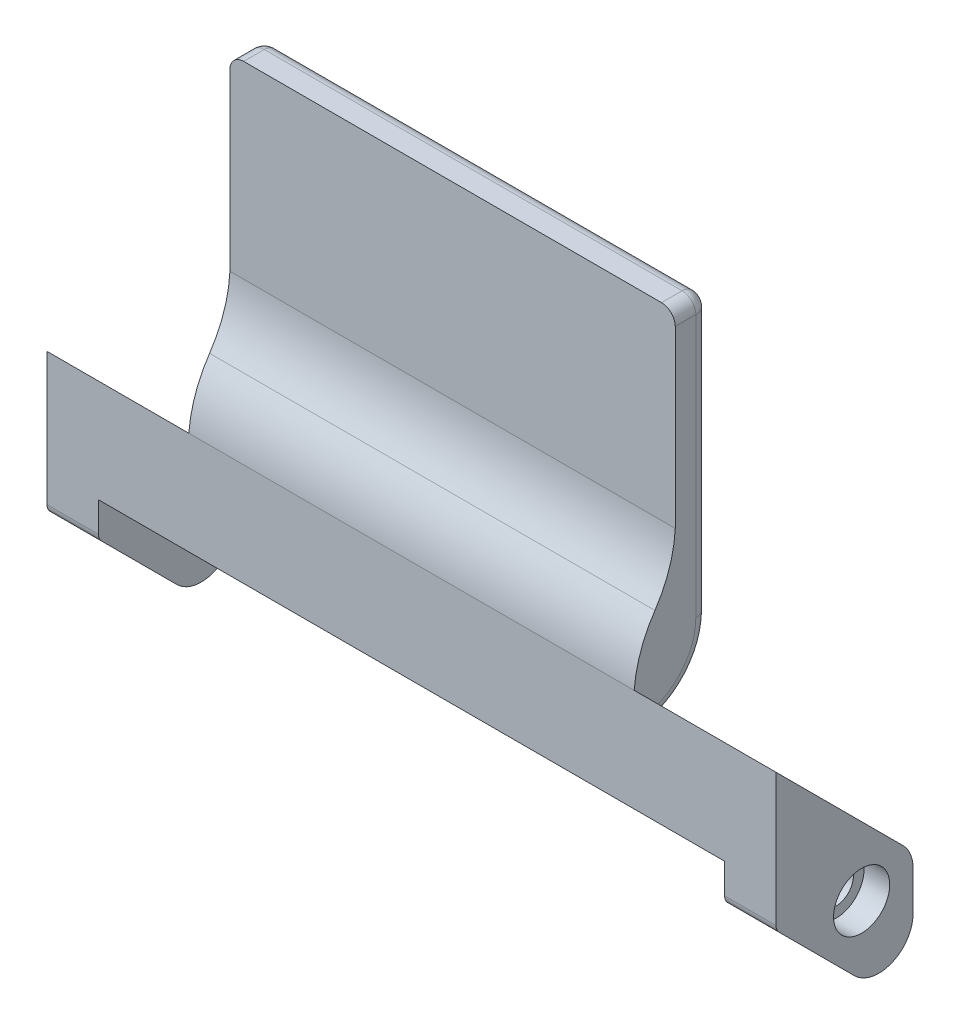
from build123d import *

# Parameters (mm, degrees)
SKETCH1_W           = 65
SKETCH1_H           = 65
BOSS_EXTRUDE1_DEPTH = 5
BOSS_EXTRUDE3_DEPTH = 7.5
BOSS_EXTRUDE5_DEPTH = 85.7
SKETCH8_R           = 2.55
CUT_EXTRUDE4_DEPTH  = 102.615648401
SKETCH8_3_R         = 4.1
SKETCH8_3_R_2       = 2.55
CUT_EXTRUDE5_DEPTH  = 3.75
SKETCH9_R           = 2.55
BOSS_EXTRUDE6_DEPTH = 7.5
SKETCH10_R          = 4.1
CUT_EXTRUDE6_DEPTH  = 3.75
BOSS_EXTRUDE7_DEPTH = 32.5
CUT_EXTRUDE7_DEPTH  = 32.5
FILLET1_R           = 5
SKETCH14_W          = 91.4
SKETCH14_H          = 5
CUT_EXTRUDE8_DEPTH  = 10
FILLET2_R           = 1.5
FILLET7_R           = 2
BOSS_EXTRUDE9_DEPTH = 65
FILLET9_R           = 2


with BuildPart() as part:
    # Sketch1 → Boss-Extrude1 (new body)
    with BuildSketch(Plane.XY):
        Rectangle(SKETCH1_W, SKETCH1_H)
    extrude(amount=BOSS_EXTRUDE1_DEPTH)



with BuildPart() as body_2:
    # Sketch4 → Boss-Extrude3 (new body)
    with BuildSketch(Plane.ZY.offset(53.2)):
        Polygon((5, -12.5), (-15, -32.5), (-15, -52.5), (5, -32.5), align=None)
    extrude(amount=-BOSS_EXTRUDE3_DEPTH)


with BuildPart() as part_1:
    add(part.part)

    add(body_2.part)  # Boss-Extrude5 merges body 2
    # Sketch7 → Boss-Extrude5 (add)
    with BuildSketch(Plane(origin=(-53.2, 0, 0), x_dir=(0, 0, -1), z_dir=(1, 0, 0))):
        Polygon((-5, -32.5), (0, -32.5), (0, -17.5), (-5, -12.5), align=None)
    boss_extrude5 = extrude(amount=BOSS_EXTRUDE5_DEPTH)

    # Sketch8 → Cut-Extrude4 (cut, through all)
    with BuildSketch(Plane.ZY.offset(53.2)):
        with Locations((-7.5, -35)):
            Circle(SKETCH8_R)
    extrude(amount=-CUT_EXTRUDE4_DEPTH, mode=Mode.SUBTRACT)

    # Sketch8_3 → Cut-Extrude5 (cut)
    with BuildSketch(Plane.ZY.offset(53.2)):
        with Locations((-7.5, -35)):
            Circle(SKETCH8_3_R)
        with Locations((-7.5, -35)):
            Circle(SKETCH8_3_R_2, mode=Mode.SUBTRACT)
    extrude(amount=-CUT_EXTRUDE5_DEPTH, mode=Mode.SUBTRACT)

    # Mirror5: Boss-Extrude5 across plane
    add(boss_extrude5.mirror(Plane(origin=(0, 0, 0), x_dir=(0, 0, 1), z_dir=(1, 0, 0))))

    # Sketch9 → Boss-Extrude6 (add)
    with BuildSketch(Plane(origin=(53.2, 0, 0), x_dir=(0, 0, -1), z_dir=(1, 0, 0))):
        Polygon((0, -17.5), (-5, -12.5), (-5, -32.5), (15, -52.5), (15, -32.5), align=None)
        with Locations(Location((7.5, -35, 0), (0, 0, 180))):
            Circle(SKETCH9_R, mode=Mode.SUBTRACT)
    extrude(amount=-BOSS_EXTRUDE6_DEPTH)

    # Sketch10 → Cut-Extrude6 (cut)
    with BuildSketch(Plane(origin=(53.2, 0, 0), x_dir=(0, 0, -1), z_dir=(1, 0, 0))):
        with Locations(Location((7.5, -35, 0), (0, 0, 180))):
            Circle(SKETCH10_R)
    extrude(amount=-CUT_EXTRUDE6_DEPTH, mode=Mode.SUBTRACT)

    # Sketch11 → Boss-Extrude7 (add, symmetric)
    with BuildSketch(Plane(origin=(0, 0, 0), x_dir=(0, 0, -1), z_dir=(1, 0, 0))):
        with BuildLine():
            Line((-5, -12.5), (-5, -32.5))
            Line((-5, -32.5), (0, -32.5))
            Line((0, -32.5), (0, -17.5))
            ThreePointArc((0, -17.5), (1.245268577, -11.245121626), (3.482006161, -5.272584286))
            ThreePointArc((3.482006161, -5.272584286), (5.362849311, 0.228699546), (6, 6.007603745))
            Line((6, 6.007603745), (6, 32.5))
            Line((6, 32.5), (1, 32.5))
            Line((1, 32.5), (1, 4.967162469))
            ThreePointArc((1, 4.967162469), (0.129503325, 0.320168795), (-1.970810175, -3.915512716))
            ThreePointArc((-1.970810175, -3.915512716), (-4.043682345, -8.010758246), (-5, -12.5))
        make_face()
    extrude(amount=BOSS_EXTRUDE7_DEPTH, both=True)

    # Sketch13 → Cut-Extrude7 (cut, symmetric)
    with BuildSketch(Plane(origin=(0, 0, 0), x_dir=(0, 0, -1), z_dir=(1, 0, 0))):
        with BuildLine():
            ThreePointArc((-1.970810175, -3.915512716), (-4.043682345, -8.010758246), (-5, -12.5))
            Line((-5, -12.5), (-5, 32.5))
            Line((-5, 32.5), (1, 32.5))
            Line((1, 32.5), (1, 4.967162469))
            ThreePointArc((1, 4.967162469), (0.129503325, 0.320168795), (-1.970810175, -3.915512716))
        make_face()
    extrude(amount=CUT_EXTRUDE7_DEPTH, both=True, mode=Mode.SUBTRACT)

    # Fillet1
    fillet1_edges = [part_1.edges().sort_by_distance(p)[0] for p in [
        (-49.45, -32.5, -15),
        (-49.45, -52.5, -15),
        (49.45, -32.5, -15),
        (49.45, -52.5, -15),
    ]]
    fillet(fillet1_edges, radius=FILLET1_R)

    # Sketch14 → Cut-Extrude8 (cut)
    with BuildSketch(Plane.XY.offset(5)):
        with Locations((0, -30)):
            Rectangle(SKETCH14_W, SKETCH14_H)
    extrude(amount=-CUT_EXTRUDE8_DEPTH, mode=Mode.SUBTRACT)

    # Fillet2
    fillet2_edges = [part_1.edges().sort_by_distance(p)[0] for p in [
        (0, -27.5, 0),
        (49.45, -32.5, 5),
        (-49.45, -32.5, 5),
    ]]
    fillet(fillet2_edges, radius=FILLET2_R)

    # Fillet7
    fillet7_edges = [part_1.edges().sort_by_distance(p)[0] for p in [
        (32.5, 32.5, -3.5),
        (-32.5, 32.5, -3.5),
    ]]
    fillet(fillet7_edges, radius=FILLET7_R)

    # Sketch16 → Boss-Extrude9 (add)
    with BuildSketch(Plane.ZY.offset(32.5)):
        with BuildLine():
            Line((-6, 6.007603745), (-6, -7.821383753))
            ThreePointArc((-6, -7.821383753), (-4.378318661, -13.515143769), (0, -17.5))
            Line((0, -17.5), (2.89677664, -14.60322336))
            Line((2.89677664, -14.60322336), (-3.112770549, 6.007603745))
            Line((-3.112770549, 6.007603745), (-6, 6.007603745))
        make_face()
    extrude(amount=-BOSS_EXTRUDE9_DEPTH)

    # Fillet9
    fillet9_edges = [part_1.edges().sort_by_distance(p)[0] for p in [
        (32.5, 11.339308123, -6),
        (-32.5, 11.339308123, -6),
        (0, 32.5, -6),
        (31.914213562, 31.914213562, -6),
        (-31.914213562, 31.914213562, -6),
        (-32.5, -13.515143769, -4.378318661),
        (32.5, -13.515143769, -4.378318661),
    ]]
    fillet(fillet9_edges, radius=FILLET9_R)


solid = part_1.part
